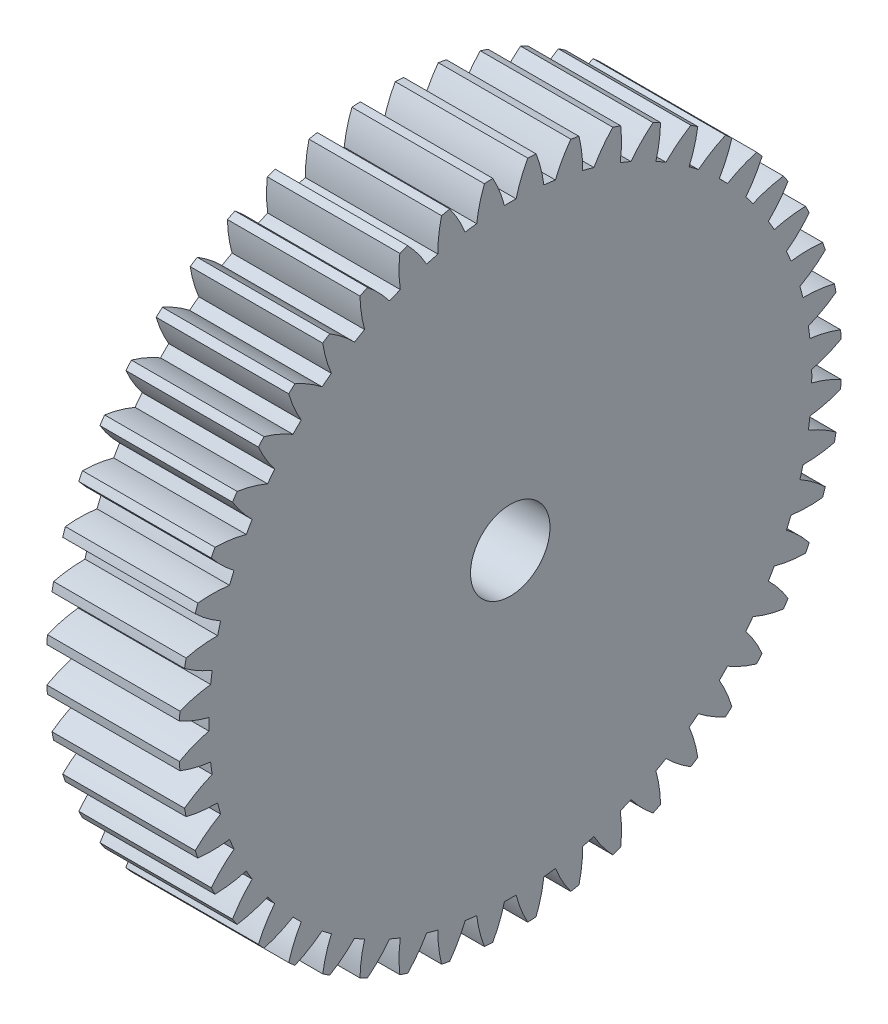
from build123d import *

# Parameters (mm, degrees)
BASPROSKE_W     = 10
BASPROSKE_H     = 25
TOOTHCUT_DEPTH  = 37.742346142
TEETHCUTS_COUNT = 48
TEETHCUTS_ANGLE = 352.5
BORSKE_R        = 3
BORE_DEPTH      = 50.0000508


with BuildPart() as part:
    # BasProSke → Base-Revolve (revolve)
    with BuildSketch(Plane(origin=(0, 0, 0), x_dir=(1, 0, 0), z_dir=(0, 1, 0)), mode=Mode.PRIVATE) as base_revolve_sk:
        with Locations((5, 12.5)):
            Rectangle(BASPROSKE_W, BASPROSKE_H)
    revolve(base_revolve_sk.sketch.rotate(Axis((-10, 0, 0), (1, 0, 0)), 180), axis=Axis((-10, 0, 0), (1, 0, 0)))

    # TooCutSke → ToothCut (cut, through all)
    with BuildSketch(Plane(origin=(0, 0, 0), x_dir=(0, 0, -1), z_dir=(1, 0, 0))):
        with BuildLine():
            ThreePointArc((0.439519311, 22.744753764), (0, 22.749), (-0.439519311, 22.744753764))
            ThreePointArc((-0.439519311, 22.744753764), (-0.815652087, 23.895542925), (-1.33363602, 24.989839138))
            ThreePointArc((-1.33363602, 24.989839138), (0, 25.0254), (1.33363602, 24.989839138))
            ThreePointArc((1.33363602, 24.989839138), (0.815652087, 23.895542925), (0.439519311, 22.744753764))
        make_face()
    toothcut = extrude(amount=TOOTHCUT_DEPTH, mode=Mode.SUBTRACT)

    # TeethCuts: ToothCut ×48 about axis
    teethcuts_axis = Axis((-10, 0, 0), (1, 0, 0))
    for i in range(1, TEETHCUTS_COUNT):
        add(toothcut.rotate(teethcuts_axis, i * TEETHCUTS_ANGLE / (TEETHCUTS_COUNT - 1)), mode=Mode.SUBTRACT)

    # BorSke → Bore (cut, symmetric)
    with BuildSketch(Plane(origin=(0, 0, 0), x_dir=(0, 0, -1), z_dir=(1, 0, 0))):
        with Locations(Location((0, 0, 0), (0, 0, 180))):
            Circle(BORSKE_R)
    extrude(amount=BORE_DEPTH, both=True, mode=Mode.SUBTRACT)


solid = part.part
